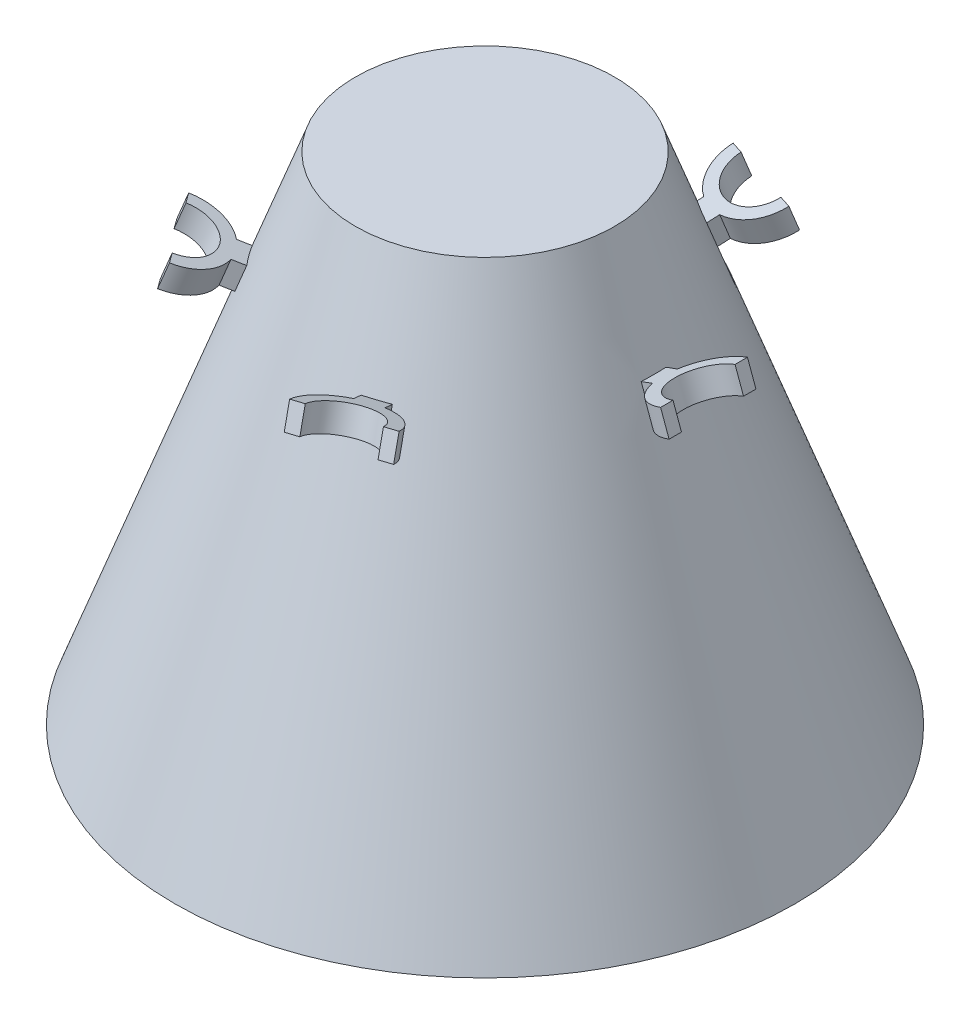
from build123d import *

# Parameters (mm, degrees)
SKETCH1_R           = 25
BOSS_EXTRUDE1_DEPTH = 40
BOSS_EXTRUDE1_TAPER = 20
BOSS_EXTRUDE2_DEPTH = 1
BOSS_EXTRUDE3_DEPTH = 2
SKETCH3_3_R         = 2.5
CUT_EXTRUDE1_DEPTH  = 2
CIRPATTERN1_COUNT   = 5


with BuildPart() as part:
    # Sketch1 → Boss-Extrude1 (new body)
    with BuildSketch(Plane(origin=(0, 0, 0), x_dir=(1, 0, 0), z_dir=(0, 1, 0))):
        Circle(SKETCH1_R)
    extrude(amount=BOSS_EXTRUDE1_DEPTH, taper=BOSS_EXTRUDE1_TAPER)

    # Sketch2 → Boss-Extrude2 (add, symmetric)
    with BuildSketch(Plane.XY):
        Polygon((13.621977962, 31.260858627), (18.320441066, 32.970959343), (19.004481353, 31.091574102), (14.306018249, 29.381473385), (12.426633007, 28.697433098), (11.742592721, 30.57681834), align=None)
    boss_extrude2 = extrude(amount=BOSS_EXTRUDE2_DEPTH, both=True)

    # Sketch3 → Boss-Extrude3 (add)
    with BuildSketch(Plane(origin=(-8.453577577, 23.226013506, 0), x_dir=(0.9396926207859088, 0.34202014332566777, 0), z_dir=(-0.34202014332566777, 0.9396926207859089, 0))):
        with BuildLine():
            Line((27.78248584, 2.5), (27.78248584, 3.5))
            ThreePointArc((27.78248584, 3.5), (24.28248584, 0), (27.78248584, -3.5))
            Line((27.78248584, -3.5), (27.78248584, -2.5))
            ThreePointArc((27.78248584, -2.5), (25.28248584, 0), (27.78248584, 2.5))
        make_face()
    boss_extrude3 = extrude(amount=-BOSS_EXTRUDE3_DEPTH)

    # Sketch3_3 → Cut-Extrude1 (cut)
    with BuildSketch(Plane(origin=(-8.453577577, 23.226013506, 0), x_dir=(0.9396926207859088, 0.34202014332566777, 0), z_dir=(-0.34202014332566777, 0.9396926207859089, 0))):
        with Locations((27.78248584, 0)):
            Circle(SKETCH3_3_R)
    cut_extrude1 = extrude(amount=-CUT_EXTRUDE1_DEPTH, mode=Mode.SUBTRACT)

    # CirPattern1: Boss-Extrude2, Boss-Extrude3, Cut-Extrude1 ×5 about axis
    cirpattern1_axis = Axis((0, 40, 0), (0, 1, 0))
    add([boss_extrude2.rotate(cirpattern1_axis, i * 360 / CIRPATTERN1_COUNT) for i in range(1, CIRPATTERN1_COUNT)])
    add([boss_extrude3.rotate(cirpattern1_axis, i * 360 / CIRPATTERN1_COUNT) for i in range(1, CIRPATTERN1_COUNT)])
    add([cut_extrude1.rotate(cirpattern1_axis, i * 360 / CIRPATTERN1_COUNT) for i in range(1, CIRPATTERN1_COUNT)], mode=Mode.SUBTRACT)


solid = part.part
